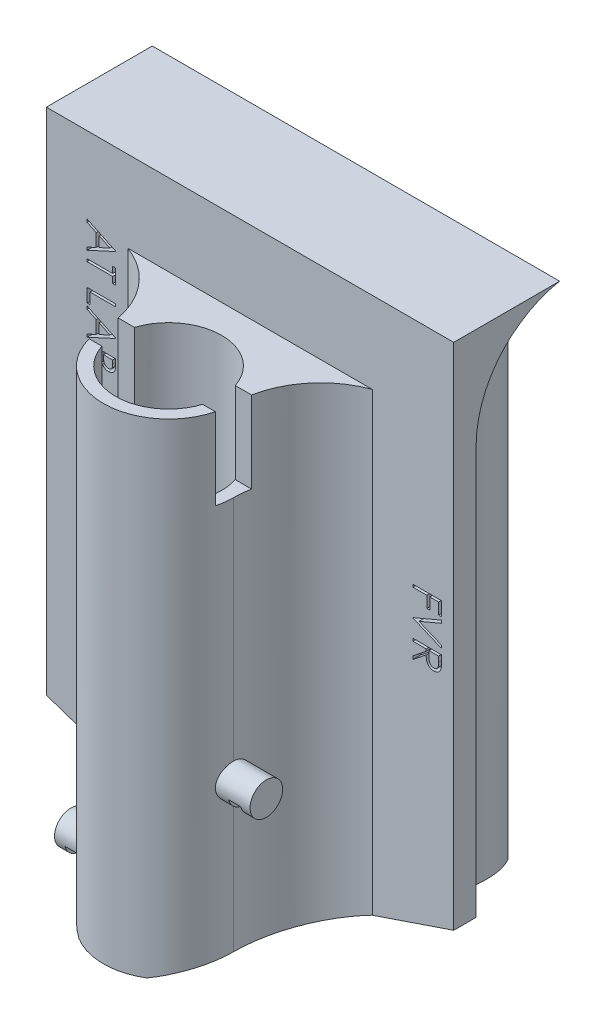
from build123d import *

# Parameters (mm, degrees)
BOSS_EXTRUDE1_DEPTH            = 13
CUT_EXTRUDE1_DEPTH             = 70.57
BOSS_EXTRUDE2_DEPTH            = 50
BOSS_EXTRUDE3_START            = -50
SKETCH4_W                      = 30
SKETCH4_H                      = 20
SKETCH4_R                      = 6.5
BOSS_EXTRUDE3_DEPTH            = 20
SKETCH5_R                      = 6.5
BOSS_EXTRUDE4_DEPTH            = 40
CUT_EXTRUDE2_DEPTH             = 25
CUT_EXTRUDE3_DEPTH             = 10
CUT_EXTRUDE6_DEPTH             = 21
CUT_EXTRUDE7_DEPTH             = 19
SKETCH12_W                     = 5
SKETCH12_H                     = 2
SKETCH13_W                     = 5
SKETCH13_H                     = 2
CUT_EXTRUDE8_REACH             = 25
SKETCH14_W                     = 1.5
SKETCH14_H                     = 1.5
CUT_EXTRUDE8_DIRECTION_2_REACH = 10
SKETCH15_W                     = 3.5
SKETCH15_H                     = 0.314102564
CUT_EXTRUDE9_DEPTH             = 1


with BuildPart() as part:
    # Sketch1 → Boss-Extrude1 (new body)
    with BuildSketch(Plane.XY):
        Polygon((0, 0), (50, 0), (50, -62.5), (29.172451618, -69.57), (20.827548382, -69.57), (0, -62.5), align=None)
    extrude(amount=BOSS_EXTRUDE1_DEPTH)

    # Sketch2 → Cut-Extrude1 (cut, through all)
    with BuildSketch(Plane(origin=(0, 0, 0), x_dir=(1, 0, 0), z_dir=(0, 1, 0))):
        with BuildLine():
            Line((0, 0), (0, -10.25))
            Line((0, -10.25), (10.16371717, -10.25))
            ThreePointArc((10.16371717, -10.25), (5.581335518, -6.12013878), (6.354560329, 0))
            Line((6.354560329, 0), (0, 0))
        make_face()
        with BuildLine():
            Line((50, -10.25), (39.83628283, -10.25))
            ThreePointArc((39.83628283, -10.25), (44.418664482, -6.12013878), (43.645439671, 0))
            Line((43.645439671, 0), (50, 0))
            Line((50, 0), (50, -10.25))
        make_face()
    extrude(amount=-CUT_EXTRUDE1_DEPTH, mode=Mode.SUBTRACT)

    # Sketch3 → Boss-Extrude2 (add)
    with BuildSketch(Plane(origin=(0, 0, 0), x_dir=(0, 0, -1), z_dir=(1, 0, 0))):
        with BuildLine():
            Line((-10.25, 0), (-10.25, -12.35))
            ThreePointArc((-10.25, -12.35), (-7.353695952, -4.32527259), (0, 0))
            Line((0, 0), (-10.25, 0))
        make_face()
    extrude(amount=BOSS_EXTRUDE2_DEPTH)

    # Sketch4 → Boss-Extrude3 (add)
    with BuildSketch(Plane(origin=(0, 0, 0), x_dir=(1, 0, 0), z_dir=(0, 1, 0)).offset(BOSS_EXTRUDE3_START)):
        with Locations((25, -23)):
            Rectangle(SKETCH4_W, SKETCH4_H)
        with Locations((25, -23)):
            Circle(SKETCH4_R, mode=Mode.SUBTRACT)
    extrude(amount=-BOSS_EXTRUDE3_DEPTH)

    # Sketch5 → Boss-Extrude4 (add)
    with BuildSketch(Plane(origin=(0, -50, 0), x_dir=(1, 0, 0), z_dir=(0, 1, 0))):
        with BuildLine():
            Line((10, -13), (40, -13))
            ThreePointArc((40, -13), (34.923888846, -16.896722192), (33, -23))
            ThreePointArc((33, -23), (25, -31), (17, -23))
            ThreePointArc((17, -23), (15.076111154, -16.896722192), (10, -13))
        make_face()
        with Locations((25, -23)):
            Circle(SKETCH5_R, mode=Mode.SUBTRACT)
    extrude(amount=BOSS_EXTRUDE4_DEPTH)

    # Sketch6 → Cut-Extrude2 (cut)
    with BuildSketch(Plane(origin=(0, -10, 0), x_dir=(1, 0, 0), z_dir=(0, 1, 0))):
        with BuildLine():
            Line((16.810391547, -21), (31.184658438, -21))
            ThreePointArc((31.184658438, -21), (30.869316877, -23), (31.184658438, -25))
            Line((31.184658438, -25), (17.254033308, -25))
            ThreePointArc((17.254033308, -25), (17.06376243, -24.00803434), (17, -23))
            ThreePointArc((17, -23), (16.952491852, -21.995516132), (16.810391547, -21))
        make_face()
    extrude(amount=-CUT_EXTRUDE2_DEPTH, mode=Mode.SUBTRACT)

    # Sketch7 → Cut-Extrude3 (cut)
    with BuildSketch(Plane(origin=(0, -10, 0), x_dir=(1, 0, 0), z_dir=(0, 1, 0))):
        with BuildLine():
            Line((31.184658438, -21), (33.189608453, -21))
            ThreePointArc((33.189608453, -21), (33.047508148, -21.995516132), (33, -23))
            ThreePointArc((33, -23), (32.93623757, -24.00803434), (32.745966692, -25))
            Line((32.745966692, -25), (31.184658438, -25))
            ThreePointArc((31.184658438, -25), (31.5, -23), (31.184658438, -21))
        make_face()
    extrude(amount=-CUT_EXTRUDE3_DEPTH, mode=Mode.SUBTRACT)

    # Sketch9 → Cut-Extrude6 (cut, through all)
    with BuildSketch(Plane(origin=(0, -50, 0), x_dir=(1, 0, 0), z_dir=(0, 1, 0))):
        with BuildLine():
            Line((10, -13), (10, -33))
            Line((10, -33), (40, -33))
            Line((40, -33), (40, -13))
            ThreePointArc((40, -13), (34.923888846, -16.896722192), (33, -23))
            ThreePointArc((33, -23), (25, -31), (17, -23))
            ThreePointArc((17, -23), (15.076111154, -16.896722192), (10, -13))
        make_face()
    extrude(amount=-CUT_EXTRUDE6_DEPTH, mode=Mode.SUBTRACT)

    # Sketch10 → Cut-Extrude7 (cut, through all)
    with BuildSketch(Plane.XY.offset(13)):
        Polygon((40, -65.894542589), (40, -70), (10, -70), (10, -65.894542589), (20.827548382, -69.57), (29.172451618, -69.57), align=None)
    extrude(amount=CUT_EXTRUDE7_DEPTH, mode=Mode.SUBTRACT)

    # Sketch12 → Revolve1 (revolve)
    with BuildSketch(Plane.XY.offset(23)):
        with Locations((15.5, -66)):
            Rectangle(SKETCH12_W, SKETCH12_H)
    revolve(axis=Axis((4.528333448, -65, 23), (1, 0, 0)))

    # Sketch13 → Revolve2 (revolve)
    with BuildSketch(Plane.XY.offset(23)):
        with Locations((34.5, -51)):
            Rectangle(SKETCH13_W, SKETCH13_H)
    revolve(axis=Axis((32, -50, 23), (1, 0, 0)))

    # Sketch14 → Cut-Extrude8 (cut, up to next)
    with BuildSketch(Plane.XY.offset(23), mode=Mode.PRIVATE) as cut_extrude8_sk1:
        with Locations((14.95, -66.25)):
            Rectangle(SKETCH14_W, SKETCH14_H)
    cut_extrude8_tool1 = extrude(cut_extrude8_sk1.sketch, amount=-CUT_EXTRUDE8_REACH, mode=Mode.PRIVATE) & part.part
    add(cut_extrude8_tool1.solids().sort_by_distance((14.95, -66.25, 23))[0], mode=Mode.SUBTRACT)
    # Sketch14 → Cut-Extrude8 (cut, up to next)
    with BuildSketch(Plane.XY.offset(23), mode=Mode.PRIVATE) as cut_extrude8_sk2:
        with Locations((35.05, -51.25)):
            Rectangle(SKETCH14_W, SKETCH14_H)
    cut_extrude8_tool2 = extrude(cut_extrude8_sk2.sketch, amount=-CUT_EXTRUDE8_REACH, mode=Mode.PRIVATE) & part.part
    add(cut_extrude8_tool2.solids().sort_by_distance((35.05, -51.25, 23))[0], mode=Mode.SUBTRACT)

    # Sketch14 → Cut-Extrude8 direction 2 (cut, up to next)
    with BuildSketch(Plane.XY.offset(23), mode=Mode.PRIVATE) as cut_extrude8_direction_2_sk1:
        with Locations((14.95, -66.25)):
            Rectangle(SKETCH14_W, SKETCH14_H)
    cut_extrude8_direction_2_tool1 = extrude(cut_extrude8_direction_2_sk1.sketch, amount=CUT_EXTRUDE8_DIRECTION_2_REACH, mode=Mode.PRIVATE) & part.part
    add(cut_extrude8_direction_2_tool1.solids().sort_by_distance((14.95, -66.25, 23))[0], mode=Mode.SUBTRACT)
    # Sketch14 → Cut-Extrude8 direction 2 (cut, up to next)
    with BuildSketch(Plane.XY.offset(23), mode=Mode.PRIVATE) as cut_extrude8_direction_2_sk2:
        with Locations((35.05, -51.25)):
            Rectangle(SKETCH14_W, SKETCH14_H)
    cut_extrude8_direction_2_tool2 = extrude(cut_extrude8_direction_2_sk2.sketch, amount=CUT_EXTRUDE8_DIRECTION_2_REACH, mode=Mode.PRIVATE) & part.part
    add(cut_extrude8_direction_2_tool2.solids().sort_by_distance((35.05, -51.25, 23))[0], mode=Mode.SUBTRACT)

    # Sketch15 → Cut-Extrude9 (cut)
    with BuildSketch(Plane.XY.offset(13)):
        Polygon((8.5, -11.098635647), (5, -12.714020263), (5, -12.372573948), (6.121794872, -11.855146064), (6.121794872, -10.268507442), (5, -9.736356), (5, -9.393507442), (8.5, -11.053763852), align=None)
        Polygon((7.817808494, -11.072694141), (6.480769231, -10.438880038), (6.480769231, -11.68968132), align=None, mode=Mode.SUBTRACT)
        Polygon((8.141025641, -12.848635647), (8.5, -12.848635647), (8.5, -14.688379237), (8.141025641, -14.688379237), (8.141025641, -13.925558724), (5, -13.925558724), (5, -13.61145616), (8.141025641, -13.61145616), align=None)
        Polygon((8.5, -16.662738211), (8.5, -16.976840775), (5.358974359, -16.976840775), (5.358974359, -18.322994622), (5, -18.322994622), (5, -16.662738211), align=None)
        Polygon((8.5, -20.342225391), (5, -21.957610006), (5, -21.616163692), (6.121794872, -21.098735807), (6.121794872, -19.512097186), (5, -18.979945743), (5, -18.637097186), (8.5, -20.297353596), align=None)
        Polygon((7.817808494, -20.316283884), (6.480769231, -19.682469782), (6.480769231, -20.933271064), align=None, mode=Mode.SUBTRACT)
        with BuildLine():
            Line((8.5, -22.496071545), (8.5, -23.178964173))
            add(Edge.make_bspline(
                [(8.5, -23.178964173), (8.49982425, -23.212392651), (8.499483602, -23.277185361), (8.49420047, -23.371404803), (8.486996801, -23.459653614), (8.475566708, -23.541957386), (8.461774931, -23.618278089), (8.445073115, -23.688845726), (8.425046501, -23.753435898), (8.39320022, -23.830548634), (8.345877051, -23.918469295), (8.275948486, -24.013667688), (8.190416023, -24.095071927), (8.093933368, -24.165258245), (7.987797596, -24.221059364), (7.874538407, -24.261428662), (7.755616665, -24.286986537), (7.673973487, -24.289614971), (7.63271234, -24.290943339)],
                knots=[0, 0, 0, 0, 0.00010027, 0.000194349, 0.000283026, 0.000365821, 0.000443519, 0.000515622, 0.000583254, 0.00064614, 0.000765662, 0.000881909, 0.000998927, 0.001118415, 0.001238844, 0.00135727, 0.001478274, 0.001601912, 0.001601912, 0.001601912, 0.001601912], degree=3))
            add(Edge.make_bspline(
                [(7.63271234, -24.290943339), (7.594053235, -24.28987125), (7.518084448, -24.287764492), (7.407150679, -24.26693284), (7.301116128, -24.235917481), (7.201287981, -24.190892344), (7.108949247, -24.132976085), (7.02464869, -24.063280552), (6.950429264, -23.980298908), (6.909109541, -23.918027246), (6.888120994, -23.886396064)],
                knots=[0, 0, 0, 0, 0.000115857, 0.00022767, 0.000337469, 0.000446673, 0.00055503, 0.000663561, 0.000773782, 0.000887567, 0.000887567, 0.000887567, 0.000887567], degree=3))
            add(Edge.make_bspline(
                [(6.888120994, -23.886396064), (6.872867775, -23.92616315), (6.843684588, -24.002247438), (6.791808319, -24.107024753), (6.736021049, -24.197659455), (6.674776106, -24.274251308), (6.607935032, -24.338768091), (6.536836284, -24.396705501), (6.45797957, -24.445244061), (6.37361028, -24.486942775), (6.284320561, -24.519759226), (6.190518767, -24.542979019), (6.093253774, -24.557246451), (6.026957798, -24.559191958), (5.993489583, -24.560174109)],
                knots=[0, 0, 0, 0, 0.000127722, 0.000244363, 0.000350193, 0.000446441, 0.000537668, 0.000628441, 0.000721042, 0.000814796, 0.000910398, 0.001005794, 0.001104254, 0.001204634, 0.001204634, 0.001204634, 0.001204634], degree=3))
            add(Edge.make_bspline(
                [(5.993489583, -24.560174109), (5.959322905, -24.559196956), (5.892099008, -24.557274381), (5.793341106, -24.543098788), (5.698976329, -24.519073588), (5.60833373, -24.486061651), (5.521926377, -24.442732118), (5.438672091, -24.391137935), (5.36078871, -24.328341276), (5.286424081, -24.25834551), (5.219600708, -24.179067776), (5.160109352, -24.093545716), (5.110959363, -24.000549241), (5.070188246, -23.901520482), (5.038590839, -23.795801388), (5.016654453, -23.683783941), (5.001839273, -23.565443799), (5.000623494, -23.484233463), (5, -23.442585968)],
                knots=[0, 0, 0, 0, 0.000102481, 0.000201635, 0.000298562, 0.000394165, 0.000490425, 0.00058808, 0.000687395, 0.000790049, 0.000894007, 0.000997858, 0.001101995, 0.00120889, 0.001318689, 0.001432403, 0.001551023, 0.001675894, 0.001675894, 0.001675894, 0.001675894], degree=3))
            Line((5, -23.442585968), (5, -22.496071545))
            Line((5, -22.496071545), (8.5, -22.496071545))
        make_face()
        with BuildLine():
            Line((8.141025641, -22.810174109), (7.019230769, -22.810174109))
            Line((7.019230769, -22.810174109), (7.019230769, -23.021211769))
            add(Edge.make_bspline(
                [(7.019230769, -23.021211769), (7.019627364, -23.052060842), (7.020393667, -23.111667538), (7.022657945, -23.198216829), (7.028720383, -23.278354148), (7.035132411, -23.352355633), (7.045005621, -23.419725295), (7.057087658, -23.480688668), (7.069753809, -23.535793394), (7.091355012, -23.599312363), (7.122955643, -23.671342031), (7.173150423, -23.747640344), (7.231312009, -23.815995608), (7.299660574, -23.873071392), (7.374282065, -23.92016889), (7.455183134, -23.951599717), (7.539205431, -23.973893189), (7.597038901, -23.975848182), (7.626402244, -23.976840775)],
                knots=[0, 0, 0, 0, 9.2559e-05, 0.000178842, 0.000259666, 0.000333617, 0.000401637, 0.000463788, 0.000520074, 0.000571069, 0.000664896, 0.000755131, 0.000844107, 0.000933161, 0.001021305, 0.001107494, 0.001192688, 0.001280555, 0.001280555, 0.001280555, 0.001280555], degree=3))
            add(Edge.make_bspline(
                [(7.626402244, -23.976840775), (7.645837164, -23.976344338), (7.683960884, -23.975370521), (7.739322416, -23.966507631), (7.792056229, -23.953647491), (7.84094948, -23.933556028), (7.887391857, -23.909261298), (7.929320542, -23.877658262), (7.969032638, -23.84196772), (8.005070015, -23.800052652), (8.037359647, -23.752116013), (8.06577169, -23.697701056), (8.088183923, -23.636158037), (8.108288888, -23.568882376), (8.122239543, -23.494797385), (8.133904149, -23.414626976), (8.13983359, -23.327691037), (8.140619428, -23.26754611), (8.141025641, -23.23645616)],
                knots=[0, 0, 0, 0, 5.8261e-05, 0.000114285, 0.000167851, 0.00022071, 0.000272469, 0.000324636, 0.000377741, 0.000432419, 0.00048998, 0.000550816, 0.000616054, 0.000686166, 0.000761242, 0.000841953, 0.000929121, 0.001022394, 0.001022394, 0.001022394, 0.001022394], degree=3))
            Line((8.141025641, -23.23645616), (8.141025641, -22.810174109))
        make_face(mode=Mode.SUBTRACT)
        with BuildLine():
            Line((6.66025641, -22.810174109), (5.358974359, -22.810174109))
            Line((5.358974359, -22.810174109), (5.358974359, -23.257489814))
            add(Edge.make_bspline(
                [(5.358974359, -23.257489814), (5.359356766, -23.289508898), (5.360093805, -23.351221463), (5.362526199, -23.44032058), (5.367942779, -23.522678948), (5.376773248, -23.598343959), (5.385948875, -23.667981671), (5.398648387, -23.730900231), (5.413086196, -23.787196099), (5.43542939, -23.852464289), (5.470080688, -23.926007655), (5.522667742, -24.005206455), (5.584492161, -24.076323727), (5.656948104, -24.136023115), (5.735135085, -24.185320528), (5.81864416, -24.21989568), (5.904927716, -24.242127008), (5.963909533, -24.244754052), (5.993489583, -24.246071545)],
                knots=[0, 0, 0, 0, 9.6064e-05, 0.000185151, 0.000267373, 0.00034356, 0.000413662, 0.000478013, 0.000536003, 0.000587886, 0.000684798, 0.000778916, 0.00087231, 0.000966388, 0.001059584, 0.001148519, 0.001236604, 0.001325223, 0.001325223, 0.001325223, 0.001325223], degree=3))
            add(Edge.make_bspline(
                [(5.993489583, -24.246071545), (6.011985316, -24.245802253), (6.048678445, -24.245268014), (6.102559382, -24.236908073), (6.154984973, -24.22524541), (6.205162465, -24.208356871), (6.253908353, -24.187061792), (6.30037356, -24.160337276), (6.345669087, -24.129475523), (6.402867072, -24.081197543), (6.468791298, -24.011042653), (6.533326389, -23.911330161), (6.585374877, -23.797959478), (6.607474256, -23.715731755), (6.618890224, -23.673255038)],
                knots=[0, 0, 0, 0, 5.5429e-05, 0.000109963, 0.000163198, 0.000216409, 0.000268519, 0.000322523, 0.000376977, 0.000432724, 0.000546819, 0.000664273, 0.000787577, 0.000919336, 0.000919336, 0.000919336, 0.000919336], degree=3))
            add(Edge.make_bspline(
                [(6.618890224, -23.673255038), (6.622345541, -23.656225958), (6.629837379, -23.6193034), (6.637740616, -23.559095514), (6.644830077, -23.490129161), (6.64993647, -23.412699115), (6.655418093, -23.326497427), (6.657474037, -23.231551791), (6.659983424, -23.127795083), (6.660163087, -23.055802622), (6.66025641, -23.018407282)],
                knots=[0, 0, 0, 0, 5.2115e-05, 0.000112995, 0.000182062, 0.000260088, 0.000345766, 0.00044116, 0.000544947, 0.000657129, 0.000657129, 0.000657129, 0.000657129], degree=3))
            Line((6.66025641, -23.018407282), (6.66025641, -22.810174109))
        make_face(mode=Mode.SUBTRACT)
        with BuildLine():
            Line((5, -26.624276673), (8.5, -26.624276673))
            Line((8.5, -26.624276673), (8.5, -27.331007442))
            add(Edge.make_bspline(
                [(8.5, -27.331007442), (8.499558636, -27.392476558), (8.498705923, -27.51123457), (8.493268378, -27.682845306), (8.483746477, -27.841402598), (8.469609165, -27.986816402), (8.452640429, -28.119320339), (8.431060433, -28.238702188), (8.405680896, -28.345155416), (8.384034427, -28.410624729), (8.373798077, -28.441584365)],
                knots=[0, 0, 0, 0, 0.000184407, 0.000356273, 0.000515031, 0.000660839, 0.000794505, 0.000915661, 0.001024663, 0.001122451, 0.001122451, 0.001122451, 0.001122451], degree=3))
            add(Edge.make_bspline(
                [(8.373798077, -28.441584365), (8.358367354, -28.482079079), (8.327855826, -28.56215022), (8.270299776, -28.676157716), (8.205085737, -28.78348169), (8.132133327, -28.884705954), (8.049356095, -28.977487676), (7.960347486, -29.065567454), (7.861470361, -29.144991316), (7.756081895, -29.218946587), (7.643112969, -29.283658658), (7.524856338, -29.340727188), (7.401533274, -29.389453749), (7.272246166, -29.427473885), (7.138236163, -29.458884994), (6.998488812, -29.4799611), (6.853818803, -29.493961104), (6.755643076, -29.495361163), (6.705829327, -29.496071545)],
                knots=[0, 0, 0, 0, 0.000129935, 0.000256923, 0.000382457, 0.000506429, 0.000630624, 0.000755071, 0.000881654, 0.001010603, 0.001140963, 0.001271727, 0.001404269, 0.001538244, 0.001675666, 0.001816872, 0.001961916, 0.002111314, 0.002111314, 0.002111314, 0.002111314], degree=3))
            add(Edge.make_bspline(
                [(6.705829327, -29.496071545), (6.662568235, -29.495442153), (6.577317734, -29.494201872), (6.451674744, -29.483078623), (6.329768825, -29.466880133), (6.212135374, -29.441916334), (6.097981959, -29.411241844), (5.987850679, -29.373380064), (5.881660811, -29.32851019), (5.780277346, -29.276452124), (5.683868003, -29.21952894), (5.594091818, -29.157115999), (5.509241366, -29.092794767), (5.433143845, -29.021605664), (5.361446986, -28.948454411), (5.298024701, -28.869461938), (5.240114366, -28.787201772), (5.188138683, -28.700089455), (5.143044021, -28.606037036), (5.104412226, -28.503760824), (5.072602821, -28.392713059), (5.04602105, -28.27306395), (5.024946939, -28.14457905), (5.010819612, -28.007140501), (5.001266947, -27.860957091), (5.000430516, -27.760577843), (5, -27.708912089)],
                knots=[0, 0, 0, 0, 0.000129755, 0.000255696, 0.000378151, 0.000498469, 0.000616165, 0.000732571, 0.000847557, 0.000961693, 0.00107424, 0.001183147, 0.00128959, 0.001393302, 0.001495449, 0.001596627, 0.001696799, 0.001797082, 0.001900566, 0.002009296, 0.002124673, 0.002246805, 0.002376823, 0.002515029, 0.002661147, 0.00281612, 0.00281612, 0.00281612, 0.00281612], degree=3))
            Line((5, -27.708912089), (5, -26.624276673))
        make_face()
        with BuildLine():
            Line((5.358974359, -26.938379237), (5.358974359, -27.340122025))
            add(Edge.make_bspline(
                [(5.358974359, -27.340122025), (5.359222455, -27.397850396), (5.359699636, -27.508883195), (5.363886839, -27.668541192), (5.370728776, -27.814420588), (5.380303854, -27.946542098), (5.392972469, -28.064831122), (5.407097372, -28.169534872), (5.424694823, -28.26031013), (5.440645782, -28.315239567), (5.448016827, -28.340622827)],
                knots=[0, 0, 0, 0, 0.000173183, 0.000333094, 0.000479096, 0.000611272, 0.000730431, 0.000835931, 0.000928194, 0.001007458, 0.001007458, 0.001007458, 0.001007458], degree=3))
            add(Edge.make_bspline(
                [(5.448016827, -28.340622827), (5.459267547, -28.372571864), (5.481500263, -28.435706837), (5.522070049, -28.526578154), (5.570067383, -28.611371199), (5.623734571, -28.691500617), (5.683902764, -28.766447537), (5.750754071, -28.835879482), (5.823549172, -28.900289927), (5.90256076, -28.958974286), (5.987278009, -29.011411851), (6.076622395, -29.057116999), (6.170378287, -29.095897143), (6.268883606, -29.127431004), (6.372045499, -29.151867933), (6.47959257, -29.16925452), (6.59155837, -29.180063215), (6.667710145, -29.181325499), (6.706530449, -29.18196898)],
                knots=[0, 0, 0, 0, 0.000101593, 0.000200759, 0.000298073, 0.000393552, 0.0004898, 0.000585999, 0.000682362, 0.000781081, 0.000880892, 0.000980919, 0.001081827, 0.00118493, 0.001290876, 0.00139957, 0.001511544, 0.001627983, 0.001627983, 0.001627983, 0.001627983], degree=3))
            add(Edge.make_bspline(
                [(6.706530449, -29.18196898), (6.747463684, -29.181455146), (6.827877387, -29.180445714), (6.945871557, -29.167779159), (7.059339618, -29.149229502), (7.168363263, -29.122547268), (7.27280065, -29.088076122), (7.373241804, -29.046828601), (7.468394145, -28.996747637), (7.559063575, -28.940050691), (7.643876965, -28.876397985), (7.721840679, -28.80607188), (7.793099946, -28.729813923), (7.857768222, -28.647975562), (7.91469547, -28.55941256), (7.965337062, -28.465623576), (8.00836517, -28.365287467), (8.031242353, -28.295473457), (8.04286859, -28.25999382)],
                knots=[0, 0, 0, 0, 0.000122746, 0.000241136, 0.000355593, 0.000467485, 0.000577457, 0.000685268, 0.000792832, 0.000899628, 0.001005778, 0.001110527, 0.001214201, 0.001318555, 0.001422987, 0.00152964, 0.001637997, 0.001749968, 0.001749968, 0.001749968, 0.001749968], degree=3))
            add(Edge.make_bspline(
                [(8.04286859, -28.25999382), (8.050985018, -28.230642674), (8.06824277, -28.168234084), (8.087068143, -28.06639462), (8.103672642, -27.95177947), (8.117730681, -27.823879769), (8.127818002, -27.68284131), (8.135389317, -27.528555622), (8.140495949, -27.360956017), (8.140844657, -27.244773484), (8.141025641, -27.184472987)],
                knots=[0, 0, 0, 0, 9.1321e-05, 0.000194173, 0.000310382, 0.000438754, 0.000580072, 0.000734511, 0.000902151, 0.001083046, 0.001083046, 0.001083046, 0.001083046], degree=3))
            Line((8.141025641, -27.184472987), (8.141025641, -26.938379237))
            Line((8.141025641, -26.938379237), (5.358974359, -26.938379237))
        make_face(mode=Mode.SUBTRACT)
        with Locations((6.75, -30.371071545)):
            Rectangle(SKETCH15_W, SKETCH15_H)
        with BuildLine():
            Line((5.675180288, -30.93196898), (5.852564103, -31.227842378))
            add(Edge.make_bspline(
                [(5.852564103, -31.227842378), (5.806499718, -31.255360615), (5.718242134, -31.308084496), (5.598984093, -31.396035855), (5.497621937, -31.487168766), (5.414745329, -31.5821581), (5.349496442, -31.680424048), (5.303294211, -31.782608102), (5.274478235, -31.888365912), (5.270978149, -31.960339734), (5.269230769, -31.996271865)],
                knots=[0, 0, 0, 0, 0.000160901, 0.00030828, 0.000443778, 0.00056903, 0.000685513, 0.000796284, 0.00090427, 0.001011928, 0.001011928, 0.001011928, 0.001011928], degree=3))
            add(Edge.make_bspline(
                [(5.269230769, -31.996271865), (5.270085441, -32.026958729), (5.271779829, -32.087795508), (5.288060647, -32.177357705), (5.313072716, -32.264339682), (5.348893869, -32.346947664), (5.392231555, -32.424045646), (5.444580544, -32.491644022), (5.503176771, -32.550119658), (5.568595717, -32.597821403), (5.63870863, -32.634852577), (5.711319991, -32.661649359), (5.786110405, -32.678703899), (5.836816049, -32.6808746), (5.862379808, -32.68196898)],
                knots=[0, 0, 0, 0, 9.1978e-05, 0.000182347, 0.000272202, 0.000362975, 0.000451852, 0.000536835, 0.000618639, 0.000699414, 0.000778765, 0.000855738, 0.000931101, 0.001007729, 0.001007729, 0.001007729, 0.001007729], degree=3))
            add(Edge.make_bspline(
                [(5.862379808, -32.68196898), (5.891520657, -32.68049467), (5.950759747, -32.677497612), (6.0381594, -32.652166132), (6.12465197, -32.612316885), (6.178153235, -32.575554241), (6.205929487, -32.556468179)],
                knots=[0, 0, 0, 0, 8.7281e-05, 0.000177429, 0.000270909, 0.000371844, 0.000371844, 0.000371844, 0.000371844], degree=3))
            add(Edge.make_bspline(
                [(6.205929487, -32.556468179), (6.226017291, -32.540841928), (6.268312913, -32.507940273), (6.330218384, -32.450593585), (6.395634226, -32.385051864), (6.464294802, -32.310987447), (6.534946198, -32.22692809), (6.609061151, -32.134599848), (6.686416915, -32.033524776), (6.737571527, -31.962291633), (6.764022436, -31.925458564)],
                knots=[0, 0, 0, 0, 7.6319e-05, 0.000160693, 0.000252906, 0.00035412, 0.000463554, 0.000582249, 0.000709297, 0.000845331, 0.000845331, 0.000845331, 0.000845331], degree=3))
            add(Edge.make_bspline(
                [(6.764022436, -31.925458564), (6.790257027, -31.88863948), (6.840415567, -31.818244194), (6.914762239, -31.71972211), (6.983169392, -31.6317398), (7.044684139, -31.553848951), (7.101989442, -31.488064697), (7.152014057, -31.43198215), (7.197429242, -31.387670407), (7.226867212, -31.363011967), (7.240084135, -31.351940936)],
                knots=[0, 0, 0, 0, 0.000135623, 0.000259301, 0.000370234, 0.000469985, 0.000556984, 0.000631925, 0.000695391, 0.000747103, 0.000747103, 0.000747103, 0.000747103], degree=3))
            add(Edge.make_bspline(
                [(7.240084135, -31.351940936), (7.260685171, -31.33646839), (7.301199875, -31.306039554), (7.364524733, -31.265873548), (7.429347998, -31.231734385), (7.495843863, -31.204972053), (7.563078792, -31.182435834), (7.631930038, -31.167277904), (7.702088656, -31.157786507), (7.749302157, -31.15681452), (7.772936699, -31.156327955)],
                knots=[0, 0, 0, 0, 7.727e-05, 0.000151962, 0.000224716, 0.000296717, 0.00036678, 0.0004372, 0.000507902, 0.000578771, 0.000578771, 0.000578771, 0.000578771], degree=3))
            add(Edge.make_bspline(
                [(7.772936699, -31.156327955), (7.809969574, -31.15762747), (7.883243772, -31.160198725), (7.990229619, -31.182121847), (8.092684247, -31.216320467), (8.188350891, -31.265781685), (8.277005834, -31.326934065), (8.357294574, -31.399206572), (8.425365503, -31.485014266), (8.484150669, -31.579686849), (8.530564015, -31.682644546), (8.565761611, -31.790338529), (8.585439222, -31.90324104), (8.588294703, -31.979840677), (8.58974359, -32.018707763)],
                knots=[0, 0, 0, 0, 0.000110999, 0.000219625, 0.000326272, 0.000434138, 0.000541492, 0.000648692, 0.000756876, 0.000868951, 0.000982216, 0.001094855, 0.001208048, 0.001324646, 0.001324646, 0.001324646, 0.001324646], degree=3))
            add(Edge.make_bspline(
                [(8.58974359, -32.018707763), (8.588347686, -32.059958011), (8.585579443, -32.141762186), (8.560648427, -32.262318233), (8.520376942, -32.378612004), (8.47399396, -32.472222792), (8.427876069, -32.545359918), (8.385853249, -32.601131684), (8.33747903, -32.657649422), (8.282619521, -32.715367392), (8.220772848, -32.773308076), (8.152362136, -32.832331521), (8.077805587, -32.892575792), (8.024581085, -32.931331652), (7.997295673, -32.95119975)],
                knots=[0, 0, 0, 0, 0.000123638, 0.000245189, 0.000367583, 0.000492063, 0.000557613, 0.000626744, 0.000701347, 0.000780694, 0.000865507, 0.000955472, 0.00105172, 0.001152964, 0.001152964, 0.001152964, 0.001152964], degree=3))
            Line((7.997295673, -32.95119975), (7.782051282, -32.667245423))
            add(Edge.make_bspline(
                [(7.782051282, -32.667245423), (7.804139973, -32.650099491), (7.846677627, -32.617080434), (7.906248935, -32.566950944), (7.960665442, -32.519702305), (8.007930479, -32.473151876), (8.050632911, -32.42975834), (8.087191686, -32.387640985), (8.11797047, -32.347407649), (8.150800721, -32.296686501), (8.183551326, -32.232800939), (8.210674418, -32.152685186), (8.227560433, -32.069190101), (8.229687874, -32.012477911), (8.230769231, -31.983651673)],
                knots=[0, 0, 0, 0, 8.3877e-05, 0.000161528, 0.000233552, 0.000299993, 0.000360485, 0.000416152, 0.000467195, 0.000512312, 0.000597287, 0.000681763, 0.000765364, 0.000851784, 0.000851784, 0.000851784, 0.000851784], degree=3))
            add(Edge.make_bspline(
                [(8.230769231, -31.983651673), (8.229557531, -31.94749515), (8.227220882, -31.877770703), (8.201700896, -31.778780467), (8.161519036, -31.689686542), (8.105204058, -31.613133977), (8.038483065, -31.549397), (7.96170421, -31.503291541), (7.876921808, -31.475541376), (7.817780151, -31.472155097), (7.787660256, -31.470430519)],
                knots=[0, 0, 0, 0, 0.000108248, 0.000208746, 0.00030443, 0.000399793, 0.000492054, 0.00057947, 0.000666386, 0.000756591, 0.000756591, 0.000756591, 0.000756591], degree=3))
            add(Edge.make_bspline(
                [(7.787660256, -31.470430519), (7.768913559, -31.470841947), (7.731389509, -31.471665476), (7.675804871, -31.482376349), (7.620713639, -31.497564046), (7.565870844, -31.519792175), (7.509986268, -31.549732467), (7.453210792, -31.590442264), (7.394110972, -31.641371895), (7.355710822, -31.680461471), (7.335436699, -31.701099589)],
                knots=[0, 0, 0, 0, 5.616e-05, 0.000112411, 0.000169233, 0.00022743, 0.000289542, 0.000358984, 0.000436553, 0.000523314, 0.000523314, 0.000523314, 0.000523314], degree=3))
            add(Edge.make_bspline(
                [(7.335436699, -31.701099589), (7.328599673, -31.708760962), (7.312356465, -31.726962629), (7.285764184, -31.760238555), (7.252961412, -31.804181353), (7.212374095, -31.857643554), (7.165292633, -31.921610916), (7.112319021, -31.996090472), (7.051733562, -32.080252005), (7.009376021, -32.139973921), (6.986979167, -32.171552314)],
                knots=[0, 0, 0, 0, 3.0802e-05, 7.3177e-05, 0.000127725, 0.000195314, 0.000274544, 0.000365991, 0.000469501, 0.000585644, 0.000585644, 0.000585644, 0.000585644], degree=3))
            add(Edge.make_bspline(
                [(6.986979167, -32.171552314), (6.959337807, -32.209538227), (6.905814145, -32.283092684), (6.825398465, -32.387750263), (6.746750697, -32.482644072), (6.67037309, -32.568107275), (6.596844997, -32.644984184), (6.525281816, -32.712421904), (6.456196244, -32.771107585), (6.367623668, -32.834286803), (6.258842584, -32.898844623), (6.125564345, -32.95428613), (5.991768025, -32.989244477), (5.901841188, -32.993815993), (5.857471955, -32.996071545)],
                knots=[0, 0, 0, 0, 0.000140932, 0.000272896, 0.000395881, 0.000510584, 0.000616697, 0.000714904, 0.000805482, 0.000888372, 0.001041088, 0.001183793, 0.001320341, 0.001453327, 0.001453327, 0.001453327, 0.001453327], degree=3))
            add(Edge.make_bspline(
                [(5.857471955, -32.996071545), (5.826093837, -32.995414041), (5.763946944, -32.994111803), (5.67268827, -32.979156198), (5.584070778, -32.95721679), (5.499109563, -32.924253494), (5.416667774, -32.883705526), (5.337504814, -32.833622965), (5.262708929, -32.773248471), (5.190723622, -32.706144665), (5.125700195, -32.631570034), (5.067544021, -32.552938222), (5.01886767, -32.469738743), (4.979683081, -32.382374293), (4.948550723, -32.291328152), (4.926173434, -32.196504505), (4.91240807, -32.097639298), (4.910981637, -32.030438224), (4.91025641, -31.996271865)],
                knots=[0, 0, 0, 0, 9.4044e-05, 0.000186263, 0.000276729, 0.000367488, 0.000459046, 0.000552021, 0.000647831, 0.000747029, 0.000846887, 0.000944209, 0.001040047, 0.001135441, 0.001231002, 0.001328276, 0.001427333, 0.001529784, 0.001529784, 0.001529784, 0.001529784], degree=3))
            add(Edge.make_bspline(
                [(4.91025641, -31.996271865), (4.910773449, -31.969837689), (4.911801015, -31.917302247), (4.920670147, -31.83980455), (4.933676836, -31.763729946), (4.953507326, -31.690033642), (4.978133645, -31.617797987), (5.00828501, -31.547666867), (5.044178677, -31.479469895), (5.085874098, -31.413127435), (5.133926601, -31.348014351), (5.189458269, -31.284464459), (5.252085534, -31.221750743), (5.322450651, -31.161022842), (5.399801843, -31.101161382), (5.484787237, -31.043279594), (5.576965667, -30.986198836), (5.6418306, -30.950383232), (5.675180288, -30.93196898)],
                knots=[0, 0, 0, 0, 7.9276e-05, 0.000157554, 0.000233748, 0.000310616, 0.000386223, 0.000462543, 0.000539379, 0.000617191, 0.000697401, 0.000781891, 0.000870138, 0.00096307, 0.001060536, 0.001163413, 0.001271399, 0.001385671, 0.001385671, 0.001385671, 0.001385671], degree=3))
        make_face()
        with BuildLine():
            Line((8.5, -33.714020263), (8.5, -34.4004185))
            add(Edge.make_bspline(
                [(8.5, -34.4004185), (8.499948104, -34.447629406), (8.499848668, -34.538087599), (8.496833922, -34.667802654), (8.49280723, -34.785612386), (8.487225337, -34.891262767), (8.480628747, -34.985078865), (8.471376708, -35.066636165), (8.461716412, -35.136575721), (8.451895005, -35.17848217), (8.447415865, -35.19759398)],
                knots=[0, 0, 0, 0, 0.000141628, 0.000271366, 0.00038923, 0.000495248, 0.00058876, 0.000671296, 0.000741499, 0.00080036, 0.00080036, 0.00080036, 0.00080036], degree=3))
            add(Edge.make_bspline(
                [(8.447415865, -35.19759398), (8.440793975, -35.221787571), (8.42770623, -35.269604661), (8.401491651, -35.338504878), (8.370412659, -35.404061791), (8.334976989, -35.46648201), (8.293734792, -35.525066017), (8.247990678, -35.580563728), (8.197769812, -35.633293461), (8.142098627, -35.681464003), (8.083029703, -35.725811172), (8.019247543, -35.763854315), (7.952140341, -35.796033792), (7.881020836, -35.822314624), (7.806321276, -35.842298194), (7.727823588, -35.857062686), (7.645797497, -35.866509191), (7.589736435, -35.867408575), (7.561197917, -35.867866416)],
                knots=[0, 0, 0, 0, 7.5216e-05, 0.00014866, 0.000220794, 0.000292713, 0.000363707, 0.000435434, 0.000508327, 0.000581868, 0.000656048, 0.000729635, 0.000804271, 0.000879029, 0.000956755, 0.00103596, 0.001118496, 0.001204079, 0.001204079, 0.001204079, 0.001204079], degree=3))
            add(Edge.make_bspline(
                [(7.561197917, -35.867866416), (7.53242014, -35.867444992), (7.476114476, -35.866620446), (7.393741688, -35.85672416), (7.315023298, -35.843393969), (7.240133847, -35.822896916), (7.169518077, -35.796051243), (7.102096845, -35.76455919), (7.039017173, -35.72657566), (6.980050055, -35.68293083), (6.925140143, -35.634379236), (6.874685348, -35.581126298), (6.82898101, -35.523387005), (6.787924666, -35.461344857), (6.752468387, -35.394395008), (6.720711082, -35.323552855), (6.694040021, -35.248202638), (6.68000996, -35.196060124), (6.672876603, -35.169549109)],
                knots=[0, 0, 0, 0, 8.6284e-05, 0.00016882, 0.000248587, 0.000325638, 0.000401297, 0.000474998, 0.000548586, 0.000621785, 0.0006948, 0.0007682, 0.000841564, 0.000915458, 0.000991056, 0.00106858, 0.00114819, 0.001230532, 0.001230532, 0.001230532, 0.001230532], degree=3))
            add(Edge.make_bspline(
                [(6.672876603, -35.169549109), (6.668213621, -35.147621775), (6.657994427, -35.099566747), (6.64658597, -35.020424025), (6.63684837, -34.928278639), (6.629547232, -34.823256359), (6.623296864, -34.705451454), (6.61832877, -34.574800197), (6.615598916, -34.43104612), (6.615458123, -34.330774876), (6.615384615, -34.278423307)],
                knots=[0, 0, 0, 0, 6.7238e-05, 0.000147357, 0.000239727, 0.000345177, 0.000463135, 0.000593636, 0.000737393, 0.000894446, 0.000894446, 0.000894446, 0.000894446], degree=3))
            Line((6.615384615, -34.278423307), (6.615384615, -34.028122827))
            Line((6.615384615, -34.028122827), (5, -34.028122827))
            Line((5, -34.028122827), (5, -33.714020263))
            Line((5, -33.714020263), (8.5, -33.714020263))
        make_face()
        with BuildLine():
            Line((8.141025641, -34.028122827), (6.974358974, -34.028122827))
            Line((6.974358974, -34.028122827), (6.966646635, -34.640903275))
            add(Edge.make_bspline(
                [(6.966646635, -34.640903275), (6.966627924, -34.670823494), (6.966591804, -34.728583859), (6.970631709, -34.812249188), (6.975087995, -34.889672187), (6.982066731, -34.961020988), (6.99126187, -35.025750342), (7.001270604, -35.084691674), (7.014830447, -35.136982115), (7.033737491, -35.198256937), (7.065355346, -35.266304033), (7.112432024, -35.339840564), (7.170792088, -35.403170506), (7.237310672, -35.457607345), (7.311578922, -35.499795752), (7.390418136, -35.531526812), (7.473877922, -35.550009973), (7.530961719, -35.552504052), (7.559795673, -35.553763852)],
                knots=[0, 0, 0, 0, 8.9746e-05, 0.000173253, 0.000251233, 0.000322392, 0.00038823, 0.000447366, 0.000501611, 0.000550171, 0.000639588, 0.000725738, 0.000811102, 0.00089684, 0.000982586, 0.001066302, 0.001151019, 0.001237488, 0.001237488, 0.001237488, 0.001237488], degree=3))
            add(Edge.make_bspline(
                [(7.559795673, -35.553763852), (7.587932, -35.552497325), (7.643863535, -35.549979626), (7.725874557, -35.531381019), (7.803877317, -35.499857694), (7.877231232, -35.45732147), (7.943477588, -35.404447686), (8.000520555, -35.342521195), (8.047000556, -35.272806495), (8.076793746, -35.207923309), (8.095014888, -35.150327238), (8.107758306, -35.100294038), (8.117934363, -35.043803756), (8.126173726, -34.980835855), (8.133227231, -34.911879059), (8.138013195, -34.836340733), (8.140814655, -34.754507093), (8.14095361, -34.697696521), (8.141025641, -34.668247025)],
                knots=[0, 0, 0, 0, 8.4371e-05, 0.000167719, 0.000250783, 0.000335923, 0.000421221, 0.000504087, 0.000587508, 0.000671588, 0.000717263, 0.000768617, 0.000826374, 0.000889338, 0.000959102, 0.001034283, 0.001116362, 0.001204706, 0.001204706, 0.001204706, 0.001204706], degree=3))
            Line((8.141025641, -34.668247025), (8.141025641, -34.028122827))
        make_face(mode=Mode.SUBTRACT)
        Polygon((5, -37.752481801), (8.5, -38.214521064), (8.5, -38.259392859), (5.628205128, -39.704404878), (8.5, -41.145911288), (8.5, -41.191484205), (5, -41.656327955), (5, -41.340823147), (7.518429487, -41.005686929), (5, -39.742265455), (5, -39.671452154), (7.524038462, -38.403122827), (5, -38.06868773), align=None)
        Polygon((8.5, -42.374276673), (8.5, -44.348635647), (8.141025641, -44.348635647), (8.141025641, -42.688379237), (7.064102564, -42.688379237), (7.064102564, -44.348635647), (6.705128205, -44.348635647), (6.705128205, -42.688379237), (5.358974359, -42.688379237), (5.358974359, -44.348635647), (5, -44.348635647), (5, -42.374276673), align=None)
        with BuildLine():
            Line((5, -44.976840775), (8.5, -44.976840775))
            Line((8.5, -44.976840775), (8.5, -45.683571545))
            add(Edge.make_bspline(
                [(8.5, -45.683571545), (8.499558636, -45.745040661), (8.498705923, -45.863798673), (8.493268378, -46.035409409), (8.483746477, -46.1939667), (8.469609165, -46.339380505), (8.452640429, -46.471884442), (8.431060433, -46.591266291), (8.405680896, -46.697719519), (8.384034427, -46.763188831), (8.373798077, -46.794148468)],
                knots=[0, 0, 0, 0, 0.000184407, 0.000356273, 0.000515031, 0.000660839, 0.000794505, 0.000915661, 0.001024663, 0.001122451, 0.001122451, 0.001122451, 0.001122451], degree=3))
            add(Edge.make_bspline(
                [(8.373798077, -46.794148468), (8.358367354, -46.834643181), (8.327855826, -46.914714323), (8.270299776, -47.028721818), (8.205085737, -47.136045792), (8.132133327, -47.237270056), (8.049356095, -47.330051779), (7.960347486, -47.418131556), (7.861470361, -47.497555418), (7.756081895, -47.571510689), (7.643112969, -47.63622276), (7.524856338, -47.693291291), (7.401533274, -47.742017851), (7.272246166, -47.780037988), (7.138236163, -47.811449097), (6.998488812, -47.832525202), (6.853818803, -47.846525206), (6.755643076, -47.847925266), (6.705829327, -47.848635647)],
                knots=[0, 0, 0, 0, 0.000129935, 0.000256923, 0.000382457, 0.000506429, 0.000630624, 0.000755071, 0.000881654, 0.001010603, 0.001140963, 0.001271727, 0.001404269, 0.001538244, 0.001675666, 0.001816872, 0.001961916, 0.002111314, 0.002111314, 0.002111314, 0.002111314], degree=3))
            add(Edge.make_bspline(
                [(6.705829327, -47.848635647), (6.662568235, -47.848006256), (6.577317734, -47.846765975), (6.451674744, -47.835642726), (6.329768825, -47.819444236), (6.212135374, -47.794480436), (6.097981959, -47.763805946), (5.987850679, -47.725944167), (5.881660811, -47.681074292), (5.780277346, -47.629016227), (5.683868003, -47.572093043), (5.594091818, -47.509680102), (5.509241366, -47.445358869), (5.433143845, -47.374169767), (5.361446986, -47.301018513), (5.298024701, -47.22202604), (5.240114366, -47.139765875), (5.188138683, -47.052653557), (5.143044021, -46.958601138), (5.104412226, -46.856324927), (5.072602821, -46.745277162), (5.04602105, -46.625628053), (5.024946939, -46.497143152), (5.010819612, -46.359704603), (5.001266947, -46.213521194), (5.000430516, -46.113141946), (5, -46.061476192)],
                knots=[0, 0, 0, 0, 0.000129755, 0.000255696, 0.000378151, 0.000498469, 0.000616165, 0.000732571, 0.000847557, 0.000961693, 0.00107424, 0.001183147, 0.00128959, 0.001393302, 0.001495449, 0.001596627, 0.001696799, 0.001797082, 0.001900566, 0.002009296, 0.002124673, 0.002246805, 0.002376823, 0.002515029, 0.002661147, 0.00281612, 0.00281612, 0.00281612, 0.00281612], degree=3))
            Line((5, -46.061476192), (5, -44.976840775))
        make_face()
        with BuildLine():
            Line((5.358974359, -45.290943339), (5.358974359, -45.692686128))
            add(Edge.make_bspline(
                [(5.358974359, -45.692686128), (5.359222455, -45.750414499), (5.359699636, -45.861447297), (5.363886839, -46.021105294), (5.370728776, -46.166984691), (5.380303854, -46.2991062), (5.392972469, -46.417395225), (5.407097372, -46.522098974), (5.424694823, -46.612874233), (5.440645782, -46.66780367), (5.448016827, -46.693186929)],
                knots=[0, 0, 0, 0, 0.000173183, 0.000333094, 0.000479096, 0.000611272, 0.000730431, 0.000835931, 0.000928194, 0.001007458, 0.001007458, 0.001007458, 0.001007458], degree=3))
            add(Edge.make_bspline(
                [(5.448016827, -46.693186929), (5.459267547, -46.725135967), (5.481500263, -46.78827094), (5.522070049, -46.879142257), (5.570067383, -46.963935302), (5.623734571, -47.044064719), (5.683902764, -47.11901164), (5.750754071, -47.188443585), (5.823549172, -47.25285403), (5.90256076, -47.311538388), (5.987278009, -47.363975954), (6.076622395, -47.409681102), (6.170378287, -47.448461246), (6.268883606, -47.479995107), (6.372045499, -47.504432036), (6.47959257, -47.521818623), (6.59155837, -47.532627317), (6.667710145, -47.533889602), (6.706530449, -47.534533083)],
                knots=[0, 0, 0, 0, 0.000101593, 0.000200759, 0.000298073, 0.000393552, 0.0004898, 0.000585999, 0.000682362, 0.000781081, 0.000880892, 0.000980919, 0.001081827, 0.00118493, 0.001290876, 0.00139957, 0.001511544, 0.001627983, 0.001627983, 0.001627983, 0.001627983], degree=3))
            add(Edge.make_bspline(
                [(6.706530449, -47.534533083), (6.747463684, -47.534019249), (6.827877387, -47.533009816), (6.945871557, -47.520343262), (7.059339618, -47.501793605), (7.168363263, -47.47511137), (7.27280065, -47.440640224), (7.373241804, -47.399392704), (7.468394145, -47.34931174), (7.559063575, -47.292614793), (7.643876965, -47.228962087), (7.721840679, -47.158635983), (7.793099946, -47.082378026), (7.857768222, -47.000539665), (7.91469547, -46.911976662), (7.965337062, -46.818187678), (8.00836517, -46.71785157), (8.031242353, -46.64803756), (8.04286859, -46.612557923)],
                knots=[0, 0, 0, 0, 0.000122746, 0.000241136, 0.000355593, 0.000467485, 0.000577457, 0.000685268, 0.000792832, 0.000899628, 0.001005778, 0.001110527, 0.001214201, 0.001318555, 0.001422987, 0.00152964, 0.001637997, 0.001749968, 0.001749968, 0.001749968, 0.001749968], degree=3))
            add(Edge.make_bspline(
                [(8.04286859, -46.612557923), (8.050985018, -46.583206776), (8.06824277, -46.520798186), (8.087068143, -46.418958722), (8.103672642, -46.304343573), (8.117730681, -46.176443872), (8.127818002, -46.035405412), (8.135389317, -45.881119724), (8.140495949, -45.71352012), (8.140844657, -45.597337586), (8.141025641, -45.537037089)],
                knots=[0, 0, 0, 0, 9.1321e-05, 0.000194173, 0.000310382, 0.000438754, 0.000580072, 0.000734511, 0.000902151, 0.001083046, 0.001083046, 0.001083046, 0.001083046], degree=3))
            Line((8.141025641, -45.537037089), (8.141025641, -45.290943339))
            Line((8.141025641, -45.290943339), (5.358974359, -45.290943339))
        make_face(mode=Mode.SUBTRACT)
        Polygon((8.5, -49.912738211), (8.5, -51.887097186), (8.141025641, -51.887097186), (8.141025641, -50.226840775), (7.064102564, -50.226840775), (7.064102564, -51.887097186), (6.705128205, -51.887097186), (6.705128205, -50.226840775), (5.358974359, -50.226840775), (5.358974359, -51.887097186), (5, -51.887097186), (5, -49.912738211), align=None)
        with BuildLine():
            Line((7.423076923, -52.649917698), (7.423076923, -52.335815134))
            add(Edge.make_bspline(
                [(7.423076923, -52.335815134), (7.464748016, -52.337861939), (7.546588934, -52.341881809), (7.665909934, -52.360715028), (7.779975252, -52.387638061), (7.887806988, -52.425794279), (7.990693283, -52.472913873), (8.087267925, -52.530601893), (8.178489406, -52.597628523), (8.262630601, -52.673870799), (8.339546174, -52.756600696), (8.406669589, -52.845322532), (8.46273344, -52.939124416), (8.5098564, -53.037192748), (8.545184955, -53.14066172), (8.571409677, -53.248542282), (8.587185182, -53.361322045), (8.588881084, -53.43816198), (8.58974359, -53.477241416)],
                knots=[0, 0, 0, 0, 0.000125083, 0.00024566, 0.000361805, 0.000476223, 0.000588214, 0.000700761, 0.000813085, 0.000927267, 0.001040885, 0.001151523, 0.001260341, 0.001368225, 0.001477317, 0.00158768, 0.001700915, 0.001818105, 0.001818105, 0.001818105, 0.001818105], degree=3))
            add(Edge.make_bspline(
                [(8.58974359, -53.477241416), (8.588845133, -53.51561949), (8.587079698, -53.591031035), (8.571918669, -53.70109305), (8.548173078, -53.805870344), (8.514857661, -53.905158111), (8.470073234, -53.998164175), (8.416275695, -54.08558722), (8.354055864, -54.16846803), (8.28080205, -54.243074814), (8.202599666, -54.311582893), (8.119111762, -54.370685148), (8.032882477, -54.421298312), (7.943254275, -54.463485992), (7.849383247, -54.494542131), (7.752636044, -54.518120339), (7.652011233, -54.531447752), (7.583904677, -54.533493176), (7.549278846, -54.534533083)],
                knots=[0, 0, 0, 0, 0.000115089, 0.000226145, 0.000332614, 0.000437044, 0.000539592, 0.000641561, 0.000744629, 0.00084975, 0.000954621, 0.001056175, 0.001156101, 0.001254284, 0.001352726, 0.001452208, 0.001552655, 0.001656537, 0.001656537, 0.001656537, 0.001656537], degree=3))
            add(Edge.make_bspline(
                [(7.549278846, -54.534533083), (7.500531012, -54.53283982), (7.403890798, -54.529483009), (7.261875935, -54.500768632), (7.124282516, -54.455922121), (7.013545214, -54.401924764), (6.92431172, -54.34745232), (6.850843015, -54.298364813), (6.771737547, -54.240900002), (6.68726021, -54.174221504), (6.596749304, -54.099708632), (6.500259509, -54.016686468), (6.398787739, -53.924562986), (6.329482138, -53.859904485), (6.293569712, -53.82640007)],
                knots=[0, 0, 0, 0, 0.000146118, 0.000289672, 0.0004329, 0.00057934, 0.000657978, 0.000746456, 0.000844345, 0.000951219, 0.001069268, 0.00119604, 0.001333047, 0.001480391, 0.001480391, 0.001480391, 0.001480391], degree=3))
            Line((6.293569712, -53.82640007), (5.358974359, -52.950698948))
            Line((5.358974359, -52.950698948), (5.358974359, -54.579404878))
            Line((5.358974359, -54.579404878), (5, -54.579404878))
            Line((5, -54.579404878), (5, -52.20119975))
            Line((5, -52.20119975), (6.448517628, -53.558571545))
            add(Edge.make_bspline(
                [(6.448517628, -53.558571545), (6.483014053, -53.591621771), (6.549274626, -53.655104492), (6.646042341, -53.744856286), (6.735709677, -53.825597496), (6.818673971, -53.89738168), (6.894464892, -53.960267904), (6.963676397, -54.014054959), (7.025714532, -54.058980575), (7.098594339, -54.106592365), (7.187681869, -54.151993367), (7.296003864, -54.191896202), (7.407759457, -54.216052835), (7.483257707, -54.218965449), (7.521233974, -54.220430519)],
                knots=[0, 0, 0, 0, 0.000143319, 0.000275286, 0.00039593, 0.000505287, 0.000604394, 0.000691344, 0.000768203, 0.00083413, 0.000952346, 0.001067236, 0.001179717, 0.001293561, 0.001293561, 0.001293561, 0.001293561], degree=3))
            add(Edge.make_bspline(
                [(7.521233974, -54.220430519), (7.545118012, -54.219801307), (7.592188863, -54.218561251), (7.661156757, -54.207409855), (7.727942288, -54.191026241), (7.7917197, -54.165774031), (7.853743372, -54.13543443), (7.91212759, -54.096673353), (7.968862533, -54.05237962), (8.022002807, -54.001001063), (8.07068755, -53.944596953), (8.113810711, -53.885000768), (8.149850063, -53.821951169), (8.179393496, -53.755710911), (8.202568894, -53.686465479), (8.218627469, -53.614080724), (8.228709954, -53.53875671), (8.230074126, -53.487323214), (8.230769231, -53.461115615)],
                knots=[0, 0, 0, 0, 7.16e-05, 0.00014111, 0.00020913, 0.000277489, 0.00034647, 0.000415895, 0.000487289, 0.000562165, 0.000637224, 0.000710578, 0.000782497, 0.000854681, 0.000927847, 0.001001157, 0.001076817, 0.00115542, 0.00115542, 0.00115542, 0.00115542], degree=3))
            add(Edge.make_bspline(
                [(8.230769231, -53.461115615), (8.230054415, -53.433744661), (8.228650634, -53.379992626), (8.218824902, -53.301075317), (8.201890229, -53.225783266), (8.178673151, -53.15396406), (8.149442666, -53.085548503), (8.112332364, -53.021155208), (8.068791169, -52.960196286), (8.019156583, -52.902783695), (7.963634417, -52.850030532), (7.902503649, -52.802706659), (7.835366634, -52.762344397), (7.763739792, -52.726565069), (7.685718657, -52.699188588), (7.603193858, -52.675787435), (7.514992916, -52.658788228), (7.454224465, -52.652923652), (7.423076923, -52.649917698)],
                knots=[0, 0, 0, 0, 8.2106e-05, 0.000161243, 0.000238127, 0.000313291, 0.000387401, 0.000460885, 0.000535787, 0.000611836, 0.00068821, 0.000765199, 0.000843238, 0.000922882, 0.001004947, 0.001090853, 0.001180094, 0.001273935, 0.001273935, 0.001273935, 0.001273935], degree=3))
        make_face()
        Polygon((48.5, -28.217225391), (48.5, -29.922353596), (48.141025641, -29.922353596), (48.141025641, -28.531327955), (47.064102564, -28.531327955), (47.064102564, -29.922353596), (46.705128205, -29.922353596), (46.705128205, -28.531327955), (45, -28.531327955), (45, -28.217225391), align=None)
        Polygon((48.5, -30.281327955), (48.5, -30.617866416), (45.741786859, -31.784533083), (48.5, -32.95119975), (48.5, -33.287738211), (45, -31.80696898), (45, -31.762097186), align=None)
        with BuildLine():
            Line((48.5, -33.960815134), (48.5, -34.661235807))
            add(Edge.make_bspline(
                [(48.5, -34.661235807), (48.499844414, -34.707976936), (48.499545672, -34.79772508), (48.497879909, -34.926298351), (48.493105553, -35.043125448), (48.48899697, -35.148145287), (48.481505028, -35.241355942), (48.474344381, -35.323043233), (48.46497072, -35.39283093), (48.456265297, -35.435076782), (48.452323718, -35.454204557)],
                knots=[0, 0, 0, 0, 0.000140226, 0.00026925, 0.000385712, 0.000490995, 0.000584507, 0.000666202, 0.000736998, 0.000795574, 0.000795574, 0.000795574, 0.000795574], degree=3))
            add(Edge.make_bspline(
                [(48.452323718, -35.454204557), (48.44599767, -35.479811633), (48.433480527, -35.530479515), (48.407010513, -35.603423037), (48.376429305, -35.672961502), (48.340231746, -35.738833953), (48.299049203, -35.8010465), (48.252641058, -35.859505994), (48.200770974, -35.913878205), (48.144763494, -35.964581502), (48.084129937, -36.010542409), (48.019753567, -36.05031556), (47.952037023, -36.084373109), (47.88074449, -36.111562275), (47.80647863, -36.133435126), (47.72859096, -36.148862778), (47.647429673, -36.158113575), (47.592071808, -36.159055485), (47.564002404, -36.159533083)],
                knots=[0, 0, 0, 0, 7.9081e-05, 0.000156475, 0.000232432, 0.000306798, 0.000381663, 0.000456012, 0.000530404, 0.000606855, 0.000682436, 0.000758316, 0.000833569, 0.000909478, 0.00098691, 0.001065561, 0.0011474, 0.001231581, 0.001231581, 0.001231581, 0.001231581], degree=3))
            add(Edge.make_bspline(
                [(47.564002404, -36.159533083), (47.517367246, -36.158064123), (47.426369973, -36.155197802), (47.294309841, -36.128472165), (47.171117785, -36.084697593), (47.056965246, -36.02436713), (46.954017226, -35.947574206), (46.863900454, -35.855286574), (46.787792734, -35.74797554), (46.735576131, -35.647606985), (46.70197773, -35.558904601), (46.678219098, -35.485664931), (46.660172121, -35.405712167), (46.643769941, -35.320193353), (46.631253759, -35.228447933), (46.622364892, -35.130660659), (46.616649282, -35.02658696), (46.615814207, -34.955247198), (46.615384615, -34.918547506)],
                knots=[0, 0, 0, 0, 0.000139777, 0.000272741, 0.000402249, 0.000530843, 0.000658588, 0.000786009, 0.00091617, 0.001051951, 0.001124085, 0.001200584, 0.001282723, 0.001369767, 0.001461782, 0.001560362, 0.001664279, 0.001774375, 0.001774375, 0.001774375, 0.001774375], degree=3))
            Line((46.615384615, -34.918547506), (45, -36.204404878))
            Line((45, -36.204404878), (45, -35.815983404))
            Line((45, -35.815983404), (46.615384615, -34.530126032))
            Line((46.615384615, -34.530126032), (46.615384615, -34.274917698))
            Line((46.615384615, -34.274917698), (45, -34.274917698))
            Line((45, -34.274917698), (45, -33.960815134))
            Line((45, -33.960815134), (48.5, -33.960815134))
        make_face()
        with BuildLine():
            Line((48.141025641, -34.274917698), (46.974358974, -34.274917698))
            Line((46.974358974, -34.274917698), (46.969451122, -34.915743019))
            add(Edge.make_bspline(
                [(46.969451122, -34.915743019), (46.969437885, -34.945663058), (46.969412229, -35.003656615), (46.973406004, -35.087557281), (46.977949327, -35.165677387), (46.984898657, -35.237718158), (46.993854777, -35.303711671), (47.005057604, -35.363625289), (47.01811018, -35.417555673), (47.038309643, -35.480457025), (47.070330282, -35.55067454), (47.116838436, -35.627080583), (47.175714061, -35.691925757), (47.241967426, -35.747834864), (47.316309813, -35.790899117), (47.395441443, -35.822242337), (47.478679147, -35.841911955), (47.53585099, -35.844250394), (47.564703526, -35.845430519)],
                knots=[0, 0, 0, 0, 8.9746e-05, 0.000173954, 0.000251933, 0.000324488, 0.000391021, 0.000451663, 0.000507268, 0.000557378, 0.000649639, 0.000738152, 0.000824558, 0.000911186, 0.000997284, 0.001081, 0.00116587, 0.001252339, 0.001252339, 0.001252339, 0.001252339], degree=3))
            add(Edge.make_bspline(
                [(47.564703526, -35.845430519), (47.592857905, -35.844246767), (47.648649611, -35.841901001), (47.730103047, -35.822204227), (47.807529909, -35.790396815), (47.879454388, -35.745795463), (47.94528638, -35.69190157), (48.000835297, -35.627894558), (48.047354277, -35.556997899), (48.076864421, -35.490687677), (48.094992971, -35.431459521), (48.107734135, -35.380027415), (48.118056983, -35.321692645), (48.126082803, -35.256595013), (48.133305124, -35.184852292), (48.137987885, -35.106268036), (48.140818147, -35.020932994), (48.140954867, -34.961785811), (48.141025641, -34.931167698)],
                knots=[0, 0, 0, 0, 8.4371e-05, 0.000167192, 0.000249871, 0.000334524, 0.000420164, 0.000504127, 0.000587748, 0.000673744, 0.000720756, 0.00077347, 0.000832606, 0.000898351, 0.000970208, 0.001048887, 0.00113447, 0.00122632, 0.00122632, 0.00122632, 0.00122632], degree=3))
            Line((48.141025641, -34.931167698), (48.141025641, -34.274917698))
        make_face(mode=Mode.SUBTRACT)
    extrude(amount=-CUT_EXTRUDE9_DEPTH, mode=Mode.SUBTRACT)


solid = part.part
